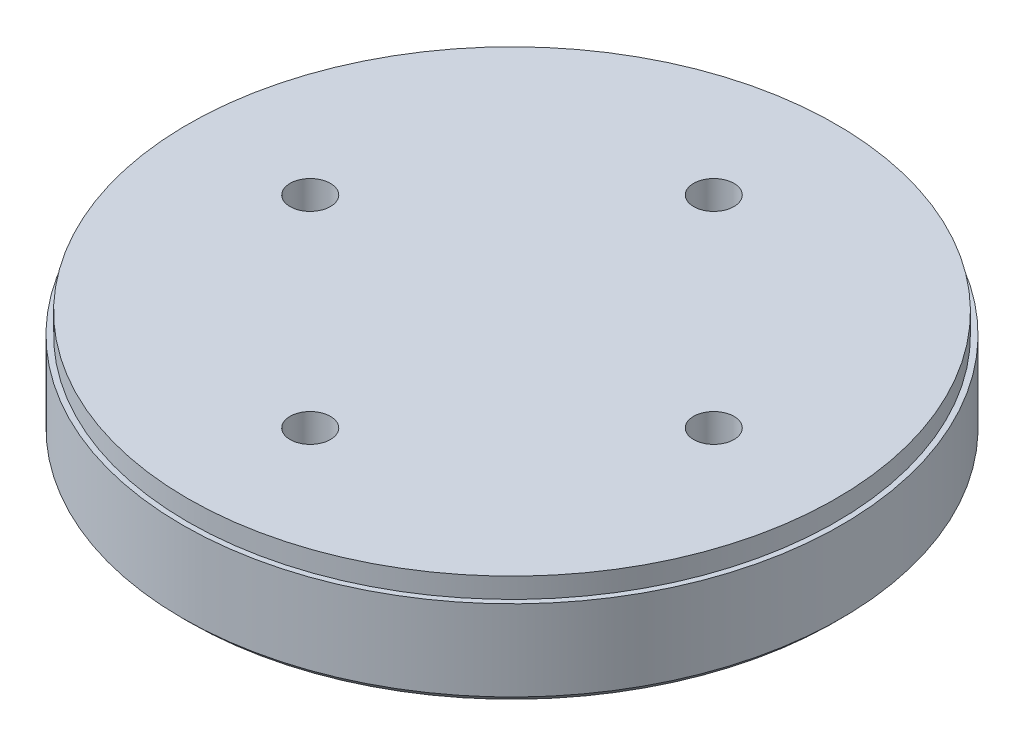
from build123d import *

# Parameters (mm, degrees)
ESQUISSE1_R             = 24.5
ESQUISSE1_R_2           = 1.5
BOSS_EXTRU_1_DEPTH      = 8
ESQUISSE2_OUTSIDE_W     = 64.952
ESQUISSE2_OUTSIDE_H     = 64.952
ESQUISSE2_OUTSIDE_R     = 24.1
ENL_V_MAT_EXTRU_1_DEPTH = 1.5
CHANFREIN1_SIZE         = 0.5


with BuildPart() as part:
    # Esquisse1 → Boss.-Extru.1 (new body)
    with BuildSketch(Plane(origin=(0, 0, 0), x_dir=(1, 0, 0), z_dir=(0, 1, 0))):
        Circle(ESQUISSE1_R)
        with Locations((0, 15)):
            Circle(ESQUISSE1_R_2, mode=Mode.SUBTRACT)
        with Locations((15, 0)):
            Circle(ESQUISSE1_R_2, mode=Mode.SUBTRACT)
        with Locations((0, -15)):
            Circle(ESQUISSE1_R_2, mode=Mode.SUBTRACT)
        with Locations((-15, 0)):
            Circle(ESQUISSE1_R_2, mode=Mode.SUBTRACT)
    extrude(amount=BOSS_EXTRU_1_DEPTH)

    # Esquisse2 outside → Enlèv. mat.-Extru.1 (cut)
    with BuildSketch(Plane(origin=(0, 8, 0), x_dir=(1, 0, 0), z_dir=(0, 1, 0))):
        Rectangle(ESQUISSE2_OUTSIDE_W, ESQUISSE2_OUTSIDE_H)
        Circle(ESQUISSE2_OUTSIDE_R, mode=Mode.SUBTRACT)
    extrude(amount=-ENL_V_MAT_EXTRU_1_DEPTH, mode=Mode.SUBTRACT)

    # Chanfrein1
    chanfrein1_edges = [part.edges().sort_by_distance(p)[0] for p in [
        (-24.5, 0, 0),
    ]]
    chamfer(chanfrein1_edges, length=CHANFREIN1_SIZE)


solid = part.part
